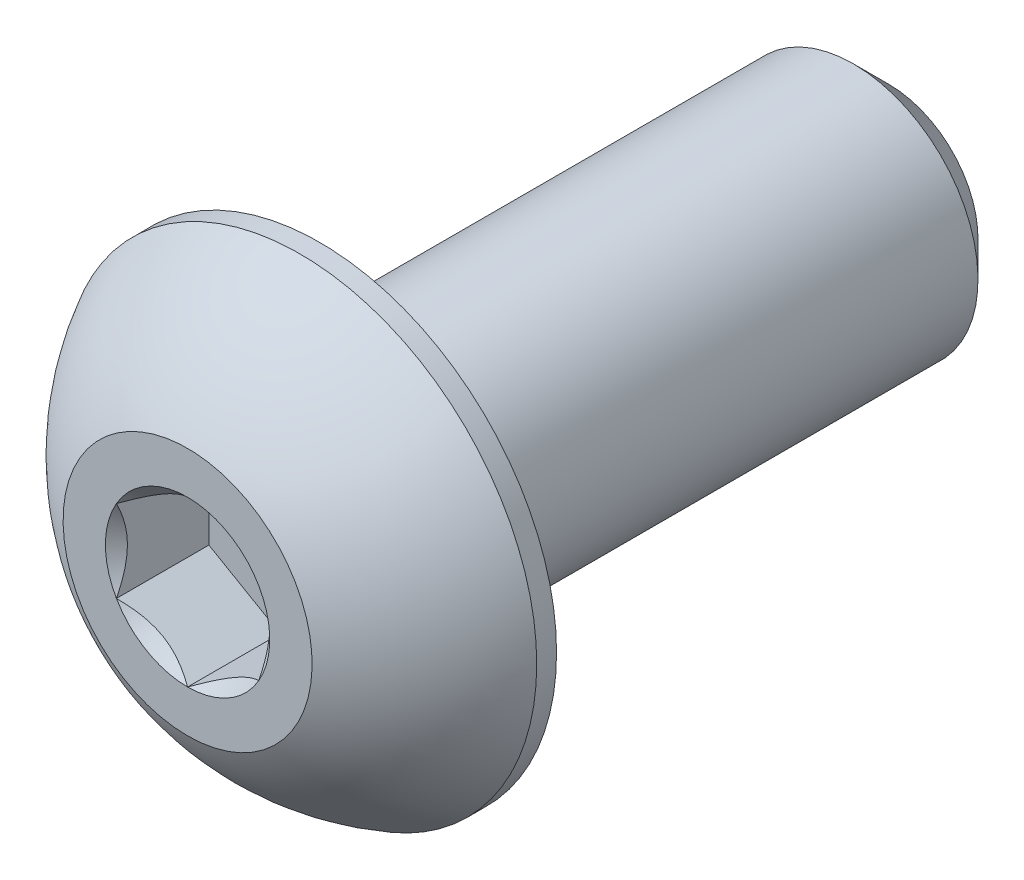
from build123d import *

# Parameters (mm, degrees)
SKETCH1_W          = 9.525
SKETCH1_H          = 2.0828
CHAMFER1_SIZE      = 0.5953125
CUT_EXTRUDE2_DEPTH = 1.54686


with BuildPart() as part:
    # Sketch1 → Revolve1 (revolve)
    with BuildSketch(Plane(origin=(0, 0, 0), x_dir=(0, 0, -1), z_dir=(1, 0, 0))):
        with Locations((6.9723, 1.0414)):
            Rectangle(SKETCH1_W, SKETCH1_H)
    revolve(axis=Axis((0, 0, -11.7348), (0, 0, 1)))

    # Chamfer1
    chamfer1_edges = [part.edges().sort_by_distance(p)[0] for p in [
        (0, -2.0828, -11.7348),
    ]]
    chamfer(chamfer1_edges, length=CHAMFER1_SIZE)

    # Sketch7 → Revolve2 (revolve)
    with BuildSketch(Plane(origin=(0, 0, 0), x_dir=(0, 0, -1), z_dir=(1, 0, 0))):
        with BuildLine():
            Line((1.87833, 3.9624), (2.2098, 3.9624))
            Line((2.2098, 3.9624), (2.2098, 0))
            Line((2.2098, 0), (0, 0))
            Line((0, 0), (0, 2.0828))
            ThreePointArc((0, 2.0828), (0.796523813, 3.165144808), (1.87833, 3.9624))
        make_face()
    revolve(axis=Axis((0, 0, 0), (0, 0, -1)))

    # Sketch5 → Cut-Extrude2 (cut)
    with BuildSketch(Plane.XY):
        Polygon((1.190625, -0.687407664), (1.190625, 0.687407664), (0, 1.374815329), (-1.190625, 0.687407664), (-1.190625, -0.687407664), (0, -1.374815329), align=None)
    extrude(amount=-CUT_EXTRUDE2_DEPTH, mode=Mode.SUBTRACT)

    # Cut-Extrude3 cone 1 section (through the dimple's axis) → Cut-Extrude3 (revolve, cut)
    with BuildSketch(Plane(origin=(0, 0, 0), x_dir=(0, -1, 0), z_dir=(1, 0, 0))):
        Polygon((0, 0), (1.374815329, 0), (0, 1.374815329), align=None)
    revolve(axis=Axis((0, 0, 0), (0, 0, -1)), mode=Mode.SUBTRACT)


solid = part.part
